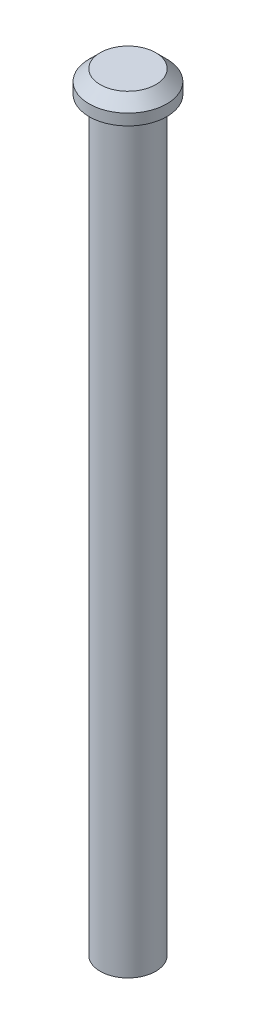
from build123d import *

# Parameters (mm, degrees)
SKETCH1_R           = 2.5
BOSS_EXTRUDE1_DEPTH = 67.21
SKETCH2_R           = 3.5
BOSS_EXTRUDE2_DEPTH = 2
CHAMFER1_SIZE       = 1
SKETCH3_R           = 1.5
CUT_EXTRUDE1_DEPTH  = 5


with BuildPart() as part:
    # Sketch1 → Boss-Extrude1 (new body)
    with BuildSketch(Plane(origin=(0, 0, 0), x_dir=(1, 0, 0), z_dir=(0, 1, 0))):
        Circle(SKETCH1_R)
    extrude(amount=BOSS_EXTRUDE1_DEPTH)

    # Sketch2 → Boss-Extrude2 (add)
    with BuildSketch(Plane(origin=(0, 67.21, 0), x_dir=(1, 0, 0), z_dir=(0, 1, 0))):
        Circle(SKETCH2_R)
    extrude(amount=BOSS_EXTRUDE2_DEPTH)

    # Chamfer1
    chamfer1_edges = [part.edges().sort_by_distance(p)[0] for p in [
        (-3.5, 69.21, 0),
    ]]
    chamfer(chamfer1_edges, length=CHAMFER1_SIZE)

    # Sketch3 → Cut-Extrude1 (cut)
    with BuildSketch(Plane.XZ):
        Circle(SKETCH3_R)
    extrude(amount=-CUT_EXTRUDE1_DEPTH, mode=Mode.SUBTRACT)


solid = part.part
